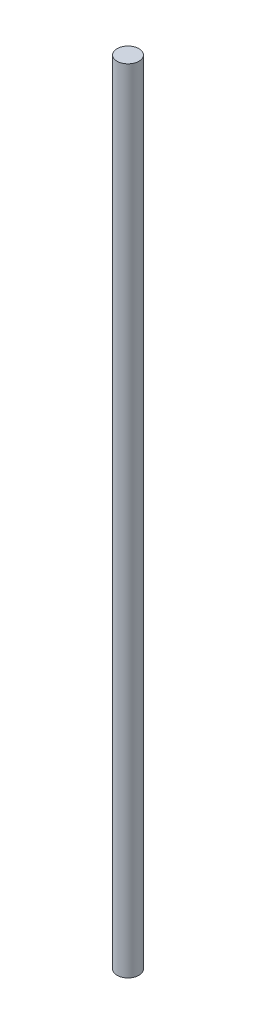
from build123d import *

# Parameters (mm, degrees)
SKETCH1_R           = 1.7526
BOSS_EXTRUDE1_DEPTH = 127


with BuildPart() as part:
    # Sketch1 → Boss-Extrude1 (new body)
    with BuildSketch(Plane(origin=(0, 0, 0), x_dir=(1, 0, 0), z_dir=(0, 1, 0))):
        Circle(SKETCH1_R)
    extrude(amount=BOSS_EXTRUDE1_DEPTH)


solid = part.part
